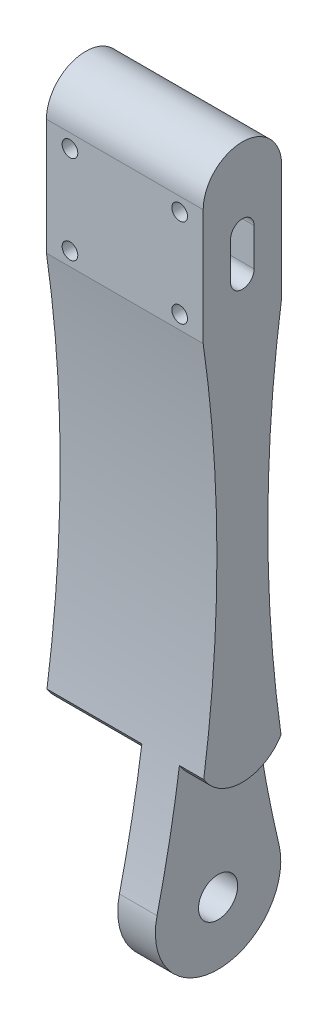
from build123d import *

# Parameters (mm, degrees)
SKETCH1_R                = 2.5
BOSS_EXTRUDE1_DEPTH      = 20
SKETCH24_W               = 8.1
SKETCH24_H               = 25
SKETCH24_W_2             = 3.1
CUT_EXTRUDE14_DEPTH      = 9
CUT_EXTRUDE14_DEPTH_BACK = 9
SKETCH25_R               = 1
CUT_EXTRUDE15_DEPTH      = 4
CUT_EXTRUDE15_DEPTH_BACK = 14
SKETCH31_W               = 4
SKETCH31_H               = 25
CUT_EXTRUDE17_DEPTH      = 4
CUT_EXTRUDE17_DEPTH_BACK = 14
BOSS_EXTRUDE5_START      = -20
BOSS_EXTRUDE5_DEPTH      = 20
SKETCH32_R               = 2.5
BOSS_EXTRUDE6_DEPTH      = 2


with BuildPart() as part:
    # Sketch1 → Boss-Extrude1 (new body)
    with BuildSketch(Plane(origin=(0, 0, 0), x_dir=(0, 0, -1), z_dir=(1, 0, 0))):
        with BuildLine():
            Line((-5, 22.270117322), (-5, 7.475642404))
            ThreePointArc((-5, 7.475642404), (-3.411481861, -24.340079768), (-7.786398999, -55.893584601))
            ThreePointArc((-7.786398999, -55.893584601), (0, -65.729882678), (7.786398999, -55.893584601))
            ThreePointArc((7.786398999, -55.893584601), (3.411481861, -24.340079768), (5, 7.475642404))
            Line((5, 7.475642404), (5, 22.270117322))
            ThreePointArc((5, 22.270117322), (0, 27.270117322), (-5, 22.270117322))
        make_face()
        with Locations((0, -57.729882678)):
            Circle(SKETCH1_R, mode=Mode.SUBTRACT)
        with BuildLine():
            Line((1.5, 12.475642404), (1.5, 17.270117322))
            ThreePointArc((1.5, 17.270117322), (0, 18.770117322), (-1.5, 17.270117322))
            Line((-1.5, 17.270117322), (-1.5, 12.475642404))
            ThreePointArc((-1.5, 12.475642404), (0, 10.975642404), (1.5, 12.475642404))
        make_face(mode=Mode.SUBTRACT)
    extrude(amount=BOSS_EXTRUDE1_DEPTH)

    # Sketch24 → Cut-Extrude14 (cut, two sides)
    with BuildSketch(Plane.XY) as cut_extrude14_sk:
        with Locations((4.05, -53.229882678)):
            Rectangle(SKETCH24_W, SKETCH24_H)
        with Locations((18.45, -53.229882678)):
            Rectangle(SKETCH24_W_2, SKETCH24_H)
    extrude(amount=CUT_EXTRUDE14_DEPTH, mode=Mode.SUBTRACT)
    extrude(cut_extrude14_sk.sketch, amount=-CUT_EXTRUDE14_DEPTH_BACK, mode=Mode.SUBTRACT)

    # Sketch25 → Cut-Extrude15 (cut, two sides)
    with BuildSketch(Plane(origin=(0, 0, -5), x_dir=(-1, 0, 0), z_dir=(0, 0, -1))) as cut_extrude15_sk:
        with Locations((-17, 9.225642404)):
            Circle(SKETCH25_R)
        with Locations((-17, 20.520117322)):
            Circle(SKETCH25_R)
        with Locations((-3, 9.225642404)):
            Circle(SKETCH25_R)
        with Locations((-3, 20.520117322)):
            Circle(SKETCH25_R)
    extrude(amount=CUT_EXTRUDE15_DEPTH, mode=Mode.SUBTRACT)
    extrude(cut_extrude15_sk.sketch, amount=-CUT_EXTRUDE15_DEPTH_BACK, mode=Mode.SUBTRACT)

    # Sketch31 → Cut-Extrude17 (cut, two sides)
    with BuildSketch(Plane.XY.offset(5)) as cut_extrude17_sk:
        with Locations((10.1, -53.229882678)):
            Rectangle(SKETCH31_W, SKETCH31_H)
    extrude(amount=CUT_EXTRUDE17_DEPTH, mode=Mode.SUBTRACT)
    extrude(cut_extrude17_sk.sketch, amount=-CUT_EXTRUDE17_DEPTH_BACK, mode=Mode.SUBTRACT)

    # Sketch26 → Boss-Extrude5 (add)
    with BuildSketch(Plane(origin=(20, 0, 0), x_dir=(0, 0, -1), z_dir=(1, 0, 0)).offset(BOSS_EXTRUDE5_START)):
        with BuildLine():
            Line((-4.929780951, -40.729882678), (4.929780951, -40.729882678))
            ThreePointArc((4.929780951, -40.729882678), (0, -43.50073532), (-4.929780951, -40.729882678))
        make_face()
    extrude(amount=BOSS_EXTRUDE5_DEPTH)

    # Sketch32 → Boss-Extrude6 (add)
    with BuildSketch(Plane.ZY.offset(-12.1)):
        with BuildLine():
            Line((-2.5, -53.227383372), (-2.5, -42.931107555))
            Line((-2.5, -42.931107555), (2.5, -42.931107555))
            Line((2.5, -42.931107555), (2.5, -53.227383372))
            ThreePointArc((2.5, -53.227383372), (0, -62.879882678), (-2.5, -53.227383372))
        make_face()
        with Locations((0, -57.729882678)):
            Circle(SKETCH32_R, mode=Mode.SUBTRACT)
    extrude(amount=BOSS_EXTRUDE6_DEPTH)


solid = part.part
